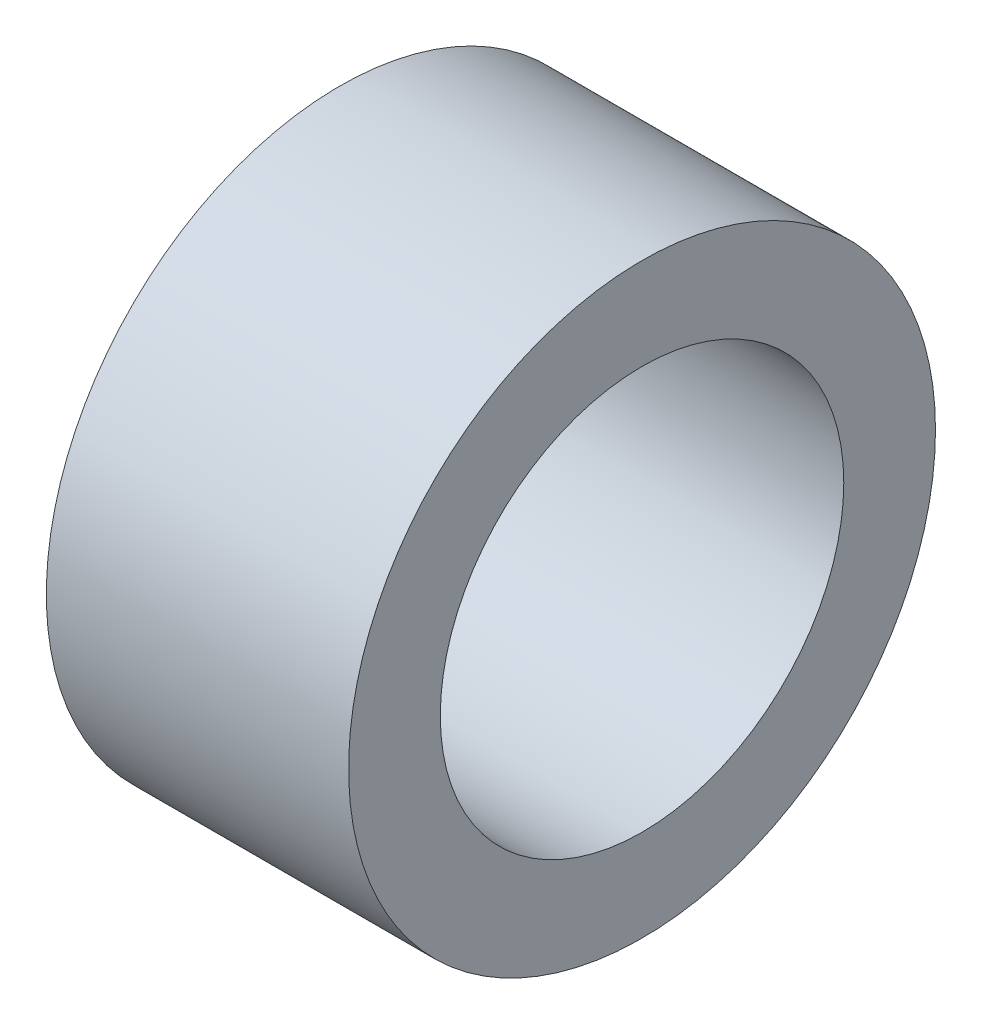
from build123d import *

# Parameters (mm, degrees)
SKETCH2_R           = 6
SKETCH2_R_2         = 4.125
BOSS_EXTRUDE1_DEPTH = 6.18


with BuildPart() as part:
    # Sketch2 → Boss-Extrude1 (new body)
    with BuildSketch(Plane(origin=(0, 0, 0), x_dir=(0, 0, -1), z_dir=(1, 0, 0))):
        Circle(SKETCH2_R)
        Circle(SKETCH2_R_2, mode=Mode.SUBTRACT)
    extrude(amount=BOSS_EXTRUDE1_DEPTH)


solid = part.part
